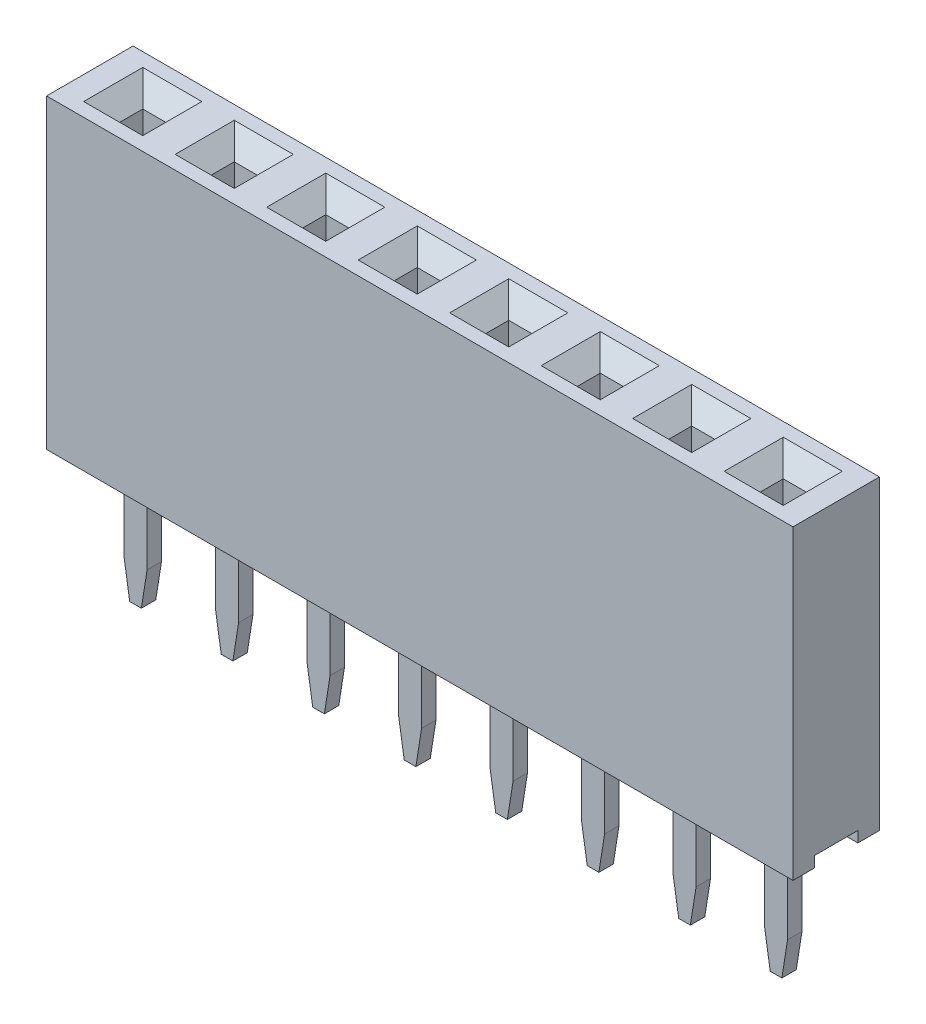
from build123d import *

# Parameters (mm, degrees)
SKETCH1_W              = 20.72
SKETCH1_H              = 2.4
BOSS_EXTRUDE1_DEPTH    = 8.5
SKETCH3_W              = 20.72
SKETCH3_H              = 1.2
CUT_EXTRUDE1_DEPTH     = 0.3
SKETCH4_W              = 0.64
SKETCH4_H              = 0.64
CUT_EXTRUDE2_DEPTH     = 6
CHAMFER2_SIZE          = 0.5
SKETCH5_W              = 0.64
SKETCH5_H              = 0.4
BOSS_EXTRUDE2_DEPTH    = 3.8
CHAMFER3_SIZE          = 1
CHAMFER3_SIZE2         = 0.15838444
CHAMFER3_PART_2_SIZE   = 1
CHAMFER3_PART_2_SIZE2  = 0.15838444
CHAMFER3_PART_3_SIZE   = 1
CHAMFER3_PART_3_SIZE2  = 0.15838444
CHAMFER3_PART_4_SIZE   = 1
CHAMFER3_PART_4_SIZE2  = 0.15838444
CHAMFER3_PART_5_SIZE   = 1
CHAMFER3_PART_5_SIZE2  = 0.15838444
CHAMFER3_PART_6_SIZE   = 1
CHAMFER3_PART_6_SIZE2  = 0.15838444
CHAMFER3_PART_7_SIZE   = 1
CHAMFER3_PART_7_SIZE2  = 0.15838444
CHAMFER3_PART_8_SIZE   = 1
CHAMFER3_PART_8_SIZE2  = 0.15838444
CHAMFER3_PART_9_SIZE   = 1
CHAMFER3_PART_9_SIZE2  = 0.15838444
CHAMFER3_PART_10_SIZE  = 1
CHAMFER3_PART_10_SIZE2 = 0.15838444
CHAMFER3_PART_11_SIZE  = 1
CHAMFER3_PART_11_SIZE2 = 0.15838444
CHAMFER3_PART_12_SIZE  = 1
CHAMFER3_PART_12_SIZE2 = 0.15838444
CHAMFER3_PART_13_SIZE  = 1
CHAMFER3_PART_13_SIZE2 = 0.15838444
CHAMFER3_PART_14_SIZE  = 1
CHAMFER3_PART_14_SIZE2 = 0.15838444
CHAMFER3_PART_15_SIZE  = 1
CHAMFER3_PART_15_SIZE2 = 0.15838444
CHAMFER3_PART_16_SIZE  = 1
CHAMFER3_PART_16_SIZE2 = 0.15838444


with BuildPart() as part:
    # Sketch1 → Boss-Extrude1 (new body)
    with BuildSketch(Plane(origin=(0, 0, 0), x_dir=(1, 0, 0), z_dir=(0, 1, 0))):
        with Locations((10.36, 1.2)):
            Rectangle(SKETCH1_W, SKETCH1_H)
    extrude(amount=BOSS_EXTRUDE1_DEPTH)

    # Sketch3 → Cut-Extrude1 (cut)
    with BuildSketch(Plane.XZ):
        with Locations((10.36, -1.2)):
            Rectangle(SKETCH3_W, SKETCH3_H)
    extrude(amount=-CUT_EXTRUDE1_DEPTH, mode=Mode.SUBTRACT)

    # Sketch4 → Cut-Extrude2 (cut)
    with BuildSketch(Plane(origin=(0, 8.5, 0), x_dir=(1, 0, 0), z_dir=(0, 1, 0))):
        with Locations((4.01, 1.2)):
            Rectangle(SKETCH4_W, SKETCH4_H)
        with Locations((1.47, 1.2)):
            Rectangle(SKETCH4_W, SKETCH4_H)
        with Locations((6.55, 1.2)):
            Rectangle(SKETCH4_W, SKETCH4_H)
        with Locations((9.09, 1.2)):
            Rectangle(SKETCH4_W, SKETCH4_H)
        with Locations((11.63, 1.2)):
            Rectangle(SKETCH4_W, SKETCH4_H)
        with Locations((14.17, 1.2)):
            Rectangle(SKETCH4_W, SKETCH4_H)
        with Locations((16.71, 1.2)):
            Rectangle(SKETCH4_W, SKETCH4_H)
        with Locations((19.25, 1.2)):
            Rectangle(SKETCH4_W, SKETCH4_H)
    extrude(amount=-CUT_EXTRUDE2_DEPTH, mode=Mode.SUBTRACT)

    # Chamfer2
    chamfer2_edges = [part.edges().sort_by_distance(p)[0] for p in [
        (1.79, 8.5, -1.2),
        (1.47, 8.5, -1.52),
        (1.15, 8.5, -1.2),
        (1.47, 8.5, -0.88),
        (4.01, 8.5, -1.52),
        (3.69, 8.5, -1.2),
        (4.01, 8.5, -0.88),
        (4.33, 8.5, -1.2),
        (6.55, 8.5, -1.52),
        (6.23, 8.5, -1.2),
        (6.55, 8.5, -0.88),
        (6.87, 8.5, -1.2),
        (9.09, 8.5, -1.52),
        (8.77, 8.5, -1.2),
        (9.09, 8.5, -0.88),
        (9.41, 8.5, -1.2),
        (11.63, 8.5, -1.52),
        (11.31, 8.5, -1.2),
        (11.63, 8.5, -0.88),
        (11.95, 8.5, -1.2),
        (14.17, 8.5, -1.52),
        (13.85, 8.5, -1.2),
        (14.17, 8.5, -0.88),
        (14.49, 8.5, -1.2),
        (16.71, 8.5, -1.52),
        (16.39, 8.5, -1.2),
        (16.71, 8.5, -0.88),
        (17.03, 8.5, -1.2),
        (19.25, 8.5, -1.52),
        (18.93, 8.5, -1.2),
        (19.25, 8.5, -0.88),
        (19.57, 8.5, -1.2),
    ]]
    chamfer(chamfer2_edges, length=CHAMFER2_SIZE)

    # Sketch5 → Boss-Extrude2 (add)
    with BuildSketch(Plane.XZ.offset(-0.3)):
        with Locations((4.01, -1.2)):
            Rectangle(SKETCH5_W, SKETCH5_H)
        with Locations((1.47, -1.2)):
            Rectangle(SKETCH5_W, SKETCH5_H)
        with Locations((6.55, -1.2)):
            Rectangle(SKETCH5_W, SKETCH5_H)
        with Locations((9.09, -1.2)):
            Rectangle(SKETCH5_W, SKETCH5_H)
        with Locations((11.63, -1.2)):
            Rectangle(SKETCH5_W, SKETCH5_H)
        with Locations((14.17, -1.2)):
            Rectangle(SKETCH5_W, SKETCH5_H)
        with Locations((16.71, -1.2)):
            Rectangle(SKETCH5_W, SKETCH5_H)
        with Locations((19.25, -1.2)):
            Rectangle(SKETCH5_W, SKETCH5_H)
    extrude(amount=BOSS_EXTRUDE2_DEPTH)

    # Chamfer3
    chamfer3_edges = [part.edges().sort_by_distance(p)[0] for p in [
        (1.79, -3.5, -1.2),
    ]]
    chamfer3_side = [part.faces().sort_by_distance(p)[0] for p in [
        (1.79, -1.6, -1.2),
    ]]
    chamfer(chamfer3_edges, length=CHAMFER3_SIZE, length2=CHAMFER3_SIZE2, reference=chamfer3_side[0])

    # Chamfer3 part 2
    chamfer3_part_2_edges = [part.edges().sort_by_distance(p)[0] for p in [
        (1.15, -3.5, -1.2),
    ]]
    chamfer3_part_2_side = [part.faces().sort_by_distance(p)[0] for p in [
        (1.15, -1.6, -1.2),
    ]]
    chamfer(chamfer3_part_2_edges, length=CHAMFER3_PART_2_SIZE, length2=CHAMFER3_PART_2_SIZE2, reference=chamfer3_part_2_side[0])

    # Chamfer3 part 3
    chamfer3_part_3_edges = [part.edges().sort_by_distance(p)[0] for p in [
        (3.69, -3.5, -1.2),
    ]]
    chamfer3_part_3_side = [part.faces().sort_by_distance(p)[0] for p in [
        (3.69, -1.6, -1.2),
    ]]
    chamfer(chamfer3_part_3_edges, length=CHAMFER3_PART_3_SIZE, length2=CHAMFER3_PART_3_SIZE2, reference=chamfer3_part_3_side[0])

    # Chamfer3 part 4
    chamfer3_part_4_edges = [part.edges().sort_by_distance(p)[0] for p in [
        (4.33, -3.5, -1.2),
    ]]
    chamfer3_part_4_side = [part.faces().sort_by_distance(p)[0] for p in [
        (4.33, -1.6, -1.2),
    ]]
    chamfer(chamfer3_part_4_edges, length=CHAMFER3_PART_4_SIZE, length2=CHAMFER3_PART_4_SIZE2, reference=chamfer3_part_4_side[0])

    # Chamfer3 part 5
    chamfer3_part_5_edges = [part.edges().sort_by_distance(p)[0] for p in [
        (6.23, -3.5, -1.2),
    ]]
    chamfer3_part_5_side = [part.faces().sort_by_distance(p)[0] for p in [
        (6.23, -1.6, -1.2),
    ]]
    chamfer(chamfer3_part_5_edges, length=CHAMFER3_PART_5_SIZE, length2=CHAMFER3_PART_5_SIZE2, reference=chamfer3_part_5_side[0])

    # Chamfer3 part 6
    chamfer3_part_6_edges = [part.edges().sort_by_distance(p)[0] for p in [
        (6.87, -3.5, -1.2),
    ]]
    chamfer3_part_6_side = [part.faces().sort_by_distance(p)[0] for p in [
        (6.87, -1.6, -1.2),
    ]]
    chamfer(chamfer3_part_6_edges, length=CHAMFER3_PART_6_SIZE, length2=CHAMFER3_PART_6_SIZE2, reference=chamfer3_part_6_side[0])

    # Chamfer3 part 7
    chamfer3_part_7_edges = [part.edges().sort_by_distance(p)[0] for p in [
        (8.77, -3.5, -1.2),
    ]]
    chamfer3_part_7_side = [part.faces().sort_by_distance(p)[0] for p in [
        (8.77, -1.6, -1.2),
    ]]
    chamfer(chamfer3_part_7_edges, length=CHAMFER3_PART_7_SIZE, length2=CHAMFER3_PART_7_SIZE2, reference=chamfer3_part_7_side[0])

    # Chamfer3 part 8
    chamfer3_part_8_edges = [part.edges().sort_by_distance(p)[0] for p in [
        (9.41, -3.5, -1.2),
    ]]
    chamfer3_part_8_side = [part.faces().sort_by_distance(p)[0] for p in [
        (9.41, -1.6, -1.2),
    ]]
    chamfer(chamfer3_part_8_edges, length=CHAMFER3_PART_8_SIZE, length2=CHAMFER3_PART_8_SIZE2, reference=chamfer3_part_8_side[0])

    # Chamfer3 part 9
    chamfer3_part_9_edges = [part.edges().sort_by_distance(p)[0] for p in [
        (11.31, -3.5, -1.2),
    ]]
    chamfer3_part_9_side = [part.faces().sort_by_distance(p)[0] for p in [
        (11.31, -1.6, -1.2),
    ]]
    chamfer(chamfer3_part_9_edges, length=CHAMFER3_PART_9_SIZE, length2=CHAMFER3_PART_9_SIZE2, reference=chamfer3_part_9_side[0])

    # Chamfer3 part 10
    chamfer3_part_10_edges = [part.edges().sort_by_distance(p)[0] for p in [
        (11.95, -3.5, -1.2),
    ]]
    chamfer3_part_10_side = [part.faces().sort_by_distance(p)[0] for p in [
        (11.95, -1.6, -1.2),
    ]]
    chamfer(chamfer3_part_10_edges, length=CHAMFER3_PART_10_SIZE, length2=CHAMFER3_PART_10_SIZE2, reference=chamfer3_part_10_side[0])

    # Chamfer3 part 11
    chamfer3_part_11_edges = [part.edges().sort_by_distance(p)[0] for p in [
        (13.85, -3.5, -1.2),
    ]]
    chamfer3_part_11_side = [part.faces().sort_by_distance(p)[0] for p in [
        (13.85, -1.6, -1.2),
    ]]
    chamfer(chamfer3_part_11_edges, length=CHAMFER3_PART_11_SIZE, length2=CHAMFER3_PART_11_SIZE2, reference=chamfer3_part_11_side[0])

    # Chamfer3 part 12
    chamfer3_part_12_edges = [part.edges().sort_by_distance(p)[0] for p in [
        (14.49, -3.5, -1.2),
    ]]
    chamfer3_part_12_side = [part.faces().sort_by_distance(p)[0] for p in [
        (14.49, -1.6, -1.2),
    ]]
    chamfer(chamfer3_part_12_edges, length=CHAMFER3_PART_12_SIZE, length2=CHAMFER3_PART_12_SIZE2, reference=chamfer3_part_12_side[0])

    # Chamfer3 part 13
    chamfer3_part_13_edges = [part.edges().sort_by_distance(p)[0] for p in [
        (16.39, -3.5, -1.2),
    ]]
    chamfer3_part_13_side = [part.faces().sort_by_distance(p)[0] for p in [
        (16.39, -1.6, -1.2),
    ]]
    chamfer(chamfer3_part_13_edges, length=CHAMFER3_PART_13_SIZE, length2=CHAMFER3_PART_13_SIZE2, reference=chamfer3_part_13_side[0])

    # Chamfer3 part 14
    chamfer3_part_14_edges = [part.edges().sort_by_distance(p)[0] for p in [
        (17.03, -3.5, -1.2),
    ]]
    chamfer3_part_14_side = [part.faces().sort_by_distance(p)[0] for p in [
        (17.03, -1.6, -1.2),
    ]]
    chamfer(chamfer3_part_14_edges, length=CHAMFER3_PART_14_SIZE, length2=CHAMFER3_PART_14_SIZE2, reference=chamfer3_part_14_side[0])

    # Chamfer3 part 15
    chamfer3_part_15_edges = [part.edges().sort_by_distance(p)[0] for p in [
        (18.93, -3.5, -1.2),
    ]]
    chamfer3_part_15_side = [part.faces().sort_by_distance(p)[0] for p in [
        (18.93, -1.6, -1.2),
    ]]
    chamfer(chamfer3_part_15_edges, length=CHAMFER3_PART_15_SIZE, length2=CHAMFER3_PART_15_SIZE2, reference=chamfer3_part_15_side[0])

    # Chamfer3 part 16
    chamfer3_part_16_edges = [part.edges().sort_by_distance(p)[0] for p in [
        (19.57, -3.5, -1.2),
    ]]
    chamfer3_part_16_side = [part.faces().sort_by_distance(p)[0] for p in [
        (19.57, -1.6, -1.2),
    ]]
    chamfer(chamfer3_part_16_edges, length=CHAMFER3_PART_16_SIZE, length2=CHAMFER3_PART_16_SIZE2, reference=chamfer3_part_16_side[0])


solid = part.part
